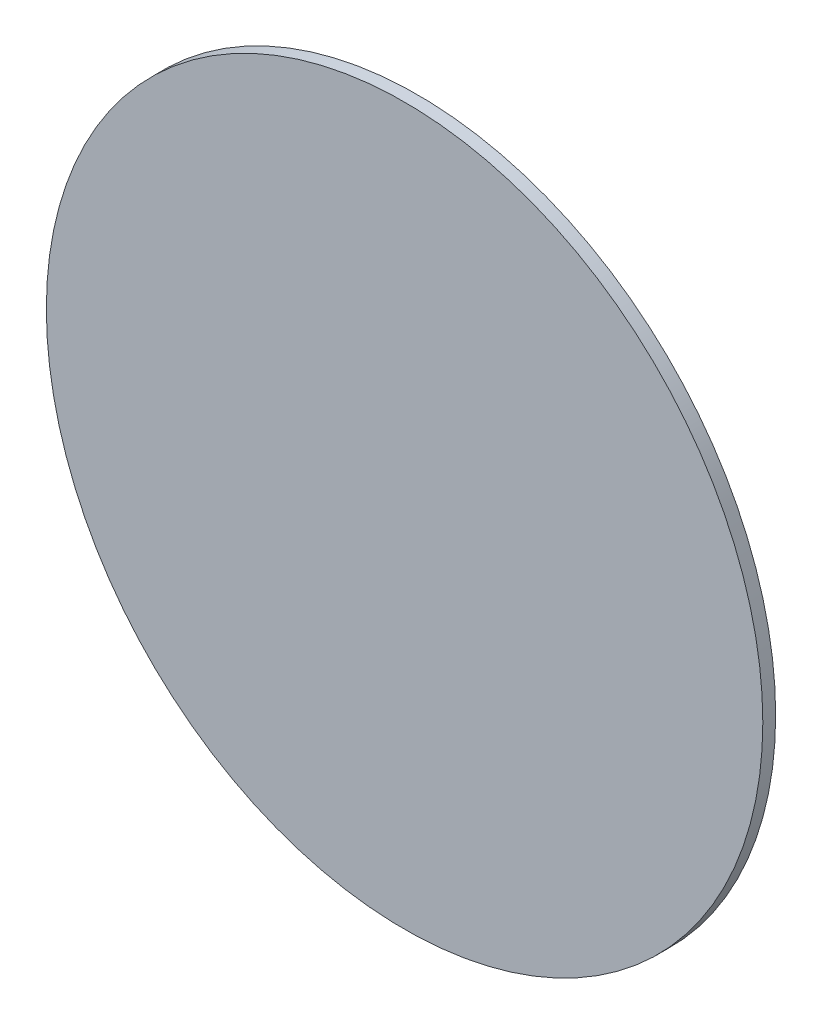
from build123d import *

# Parameters (mm, degrees)
SKETCH1_R           = 278.896456497
BOSS_EXTRUDE1_DEPTH = 10


with BuildPart() as part:
    # Sketch1 → Boss-Extrude1 (new body)
    with BuildSketch(Plane.XY):
        with Locations((-10678.630104293, 9168.811301952)):
            Circle(SKETCH1_R)
    extrude(amount=BOSS_EXTRUDE1_DEPTH)


solid = part.part
